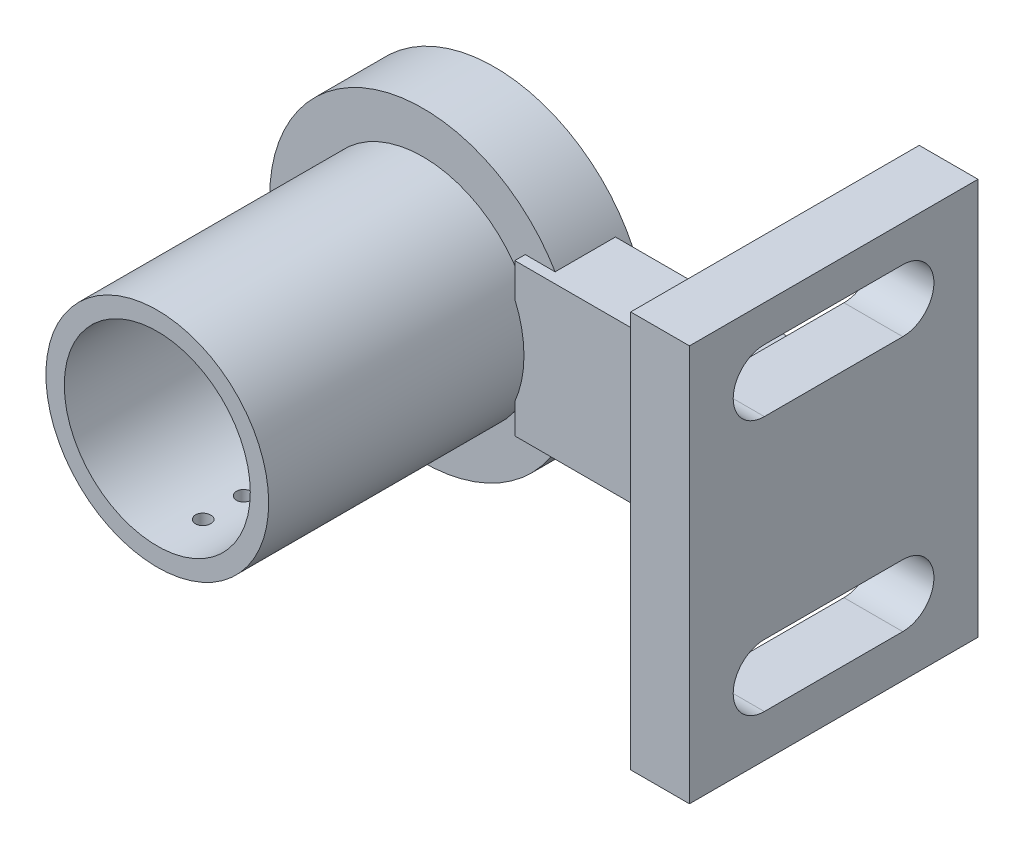
from build123d import *

# Parameters (mm, degrees)
SKETCH2_R                = 15
SKETCH2_R_2              = 13.05
BOSS_EXTRUDE2_DEPTH      = 16
BOSS_EXTRUDE2_DEPTH_BACK = 8
SKETCH1_R                = 15
SKETCH1_R_2              = 9.1
BOSS_EXTRUDE3_DEPTH      = 28
SKETCH4_R                = 15
SKETCH4_R_2              = 10.9
CUT_EXTRUDE2_DEPTH       = 29
SKETCH5_W                = 6.921152332
SKETCH5_H                = 14.857061979
BOSS_EXTRUDE4_DEPTH      = 22
SKETCH3_R                = 0.75
CUT_EXTRUDE1_DEPTH       = 16
SKETCH6_R                = 15
SKETCH6_R_2              = 10.9
BOSS_EXTRUDE5_DEPTH      = 2
SKETCH7_W                = 28.232901182
SKETCH7_H                = 38.810832399
BOSS_EXTRUDE6_DEPTH      = 5.75
CUT_EXTRUDE3_DEPTH       = 8
SKETCH15_R               = 13
CUT_EXTRUDE6_DEPTH       = 5


with BuildPart() as part:
    # Sketch2 → Boss-Extrude2 (new body, two sides)
    with BuildSketch(Plane.XY.offset(3)) as boss_extrude2_sk:
        Circle(SKETCH2_R)
        Circle(SKETCH2_R_2, mode=Mode.SUBTRACT)
    extrude(amount=BOSS_EXTRUDE2_DEPTH)
    extrude(boss_extrude2_sk.sketch, amount=-BOSS_EXTRUDE2_DEPTH_BACK)

    # Sketch1 → Boss-Extrude3 (add)
    with BuildSketch(Plane.XY):
        Circle(SKETCH1_R)
        Circle(SKETCH1_R_2, mode=Mode.SUBTRACT)
    extrude(amount=BOSS_EXTRUDE3_DEPTH)

    # Sketch4 → Cut-Extrude2 (cut)
    with BuildSketch(Plane(origin=(0, 0, 0), x_dir=(-1, 0, 0), z_dir=(0, 0, -1))):
        Circle(SKETCH4_R)
        Circle(SKETCH4_R_2, mode=Mode.SUBTRACT)
    extrude(amount=-CUT_EXTRUDE2_DEPTH, mode=Mode.SUBTRACT)

    # Sketch5 → Boss-Extrude4 (add)
    with BuildSketch(Plane(origin=(10, 0, 0), x_dir=(0, 0, -1), z_dir=(1, 0, 0))):
        with Locations((0.440387125, 0.176739876)):
            Rectangle(SKETCH5_W, SKETCH5_H)
    extrude(amount=BOSS_EXTRUDE4_DEPTH)

    # Sketch3 → Cut-Extrude1 (cut, through all)
    with BuildSketch(Plane(origin=(0, 0, 0), x_dir=(1, 0, 0), z_dir=(0, 1, 0))):
        with Locations((0, -3.5)):
            Circle(SKETCH3_R)
        with Locations((0, -7.5)):
            Circle(SKETCH3_R)
        with Locations((0, -11.5)):
            Circle(SKETCH3_R)
        with Locations((0, -15.5)):
            Circle(SKETCH3_R)
        with Locations((0, -19.5)):
            Circle(SKETCH3_R)
        with Locations((0, -23.5)):
            Circle(SKETCH3_R)
    extrude(amount=-CUT_EXTRUDE1_DEPTH, mode=Mode.SUBTRACT)

    # Sketch6 → Boss-Extrude5 (add)
    with BuildSketch(Plane.XY):
        Circle(SKETCH6_R)
        Circle(SKETCH6_R_2, mode=Mode.SUBTRACT)
    extrude(amount=BOSS_EXTRUDE5_DEPTH)

    # Sketch7 → Boss-Extrude6 (add)
    with BuildSketch(Plane(origin=(32, 0, 0), x_dir=(0, 0, -1), z_dir=(1, 0, 0))):
        with Locations((0.440387125, 0.176739875)):
            Rectangle(SKETCH7_W, SKETCH7_H)
    extrude(amount=BOSS_EXTRUDE6_DEPTH)

    # Sketch9 → Cut-Extrude3 (cut)
    with BuildSketch(Plane.ZY.offset(-32)):
        with BuildLine():
            Line((-7.192763814, 16.024728338), (6.347778577, 16.024728338))
            ThreePointArc((6.347778577, 16.024728338), (9.397778577, 12.974728338), (6.347778577, 9.924728338))
            Line((6.347778577, 9.924728338), (-7.192763814, 9.924728338))
            ThreePointArc((-7.192763814, 9.924728338), (-10.242763814, 12.974728338), (-7.192763814, 16.024728338))
        make_face()
        with BuildLine():
            Line((-7.192763814, -8.96717342), (6.347778577, -8.96717342))
            ThreePointArc((6.347778577, -8.96717342), (9.397778577, -12.01717342), (6.347778577, -15.06717342))
            Line((6.347778577, -15.06717342), (-7.192763814, -15.06717342))
            ThreePointArc((-7.192763814, -15.06717342), (-10.242763814, -12.01717342), (-7.192763814, -8.96717342))
        make_face()
    extrude(amount=-CUT_EXTRUDE3_DEPTH, mode=Mode.SUBTRACT)

    # Sketch15 → Cut-Extrude6 (cut)
    with BuildSketch(Plane(origin=(0, 0, -5), x_dir=(-1, 0, 0), z_dir=(0, 0, -1))):
        Circle(SKETCH15_R)
    extrude(amount=-CUT_EXTRUDE6_DEPTH, mode=Mode.SUBTRACT)


solid = part.part
